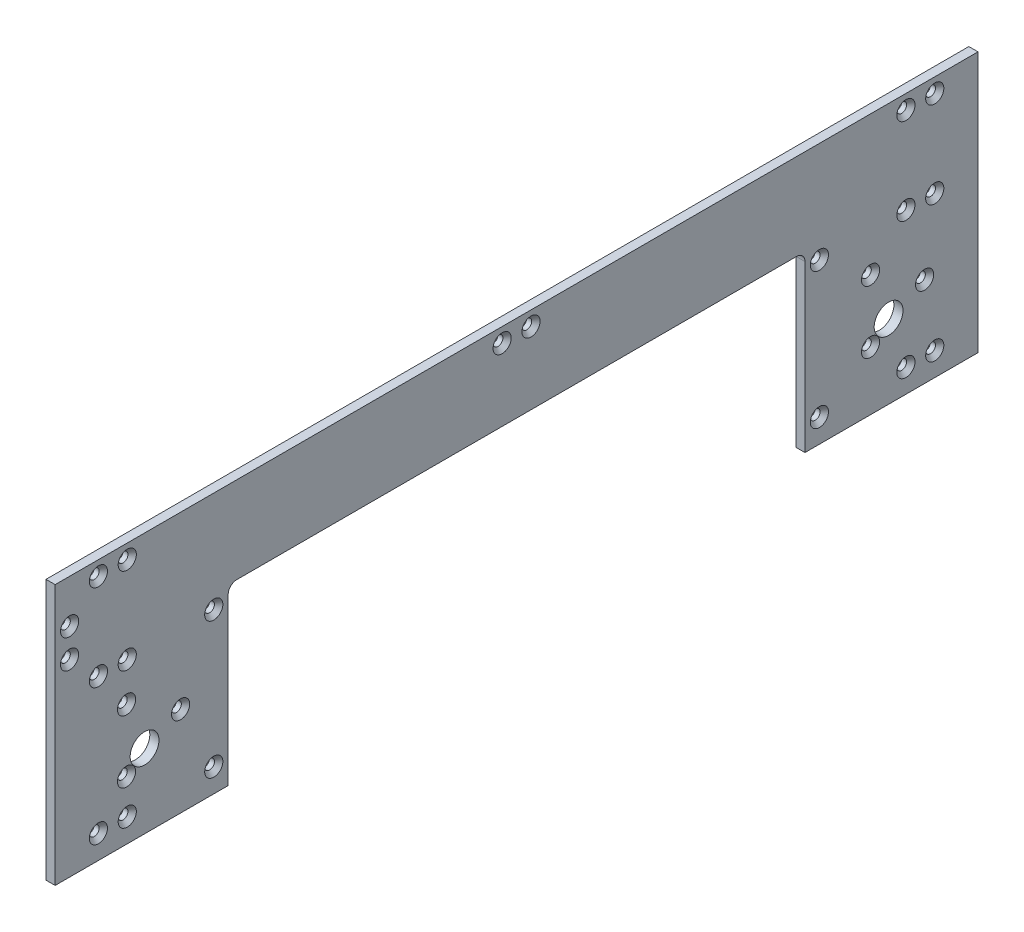
from build123d import *

# Parameters (mm, degrees)
BOSS_EXTRUDE1_DEPTH                             = 3.175
CSK_FOR_M3_FLAT_HEAD_MACHINE_SCREW1_D           = 3.4
CSK_FOR_M3_FLAT_HEAD_MACHINE_SCREW1_CSINK_D     = 6.3
CSK_FOR_M3_FLAT_HEAD_MACHINE_SCREW1_CSINK_ANGLE = 90
SKETCH4_R                                       = 5
CUT_EXTRUDE1_DEPTH                              = 4.175
CSK_FOR_M3_FLAT_HEAD_MACHINE_SCREW2_D           = 3.4
CSK_FOR_M3_FLAT_HEAD_MACHINE_SCREW2_CSINK_D     = 6.3
CSK_FOR_M3_FLAT_HEAD_MACHINE_SCREW2_CSINK_ANGLE = 90
CSK_FOR_M3_FLAT_HEAD_MACHINE_SCREW3_D           = 3.4
CSK_FOR_M3_FLAT_HEAD_MACHINE_SCREW3_CSINK_D     = 6.3
CSK_FOR_M3_FLAT_HEAD_MACHINE_SCREW3_CSINK_ANGLE = 90
LPATTERN1_COUNT                                 = 2
LPATTERN1_PITCH                                 = 258


with BuildPart() as part:
    # Sketch1 → Boss-Extrude1 (new body)
    with BuildSketch(Plane(origin=(0, 0, 0), x_dir=(0, 0, -1), z_dir=(1, 0, 0))):
        Polygon((160, 0), (160, 3.175), (160, 47.175), (160, 50.35), (160, 60.35), (160, 90.35), (-160, 90.35), (-160, 60.35), (-160, 50.35), (-160, 47.175), (-160, 3.175), (-160, 0), align=None)
    extrude(amount=BOSS_EXTRUDE1_DEPTH)

    # CSK for M3 Flat Head Machine Screw1 (through all)
    with Locations(Plane(origin=(3.175, 0, 0), x_dir=(0, 0, -1), z_dir=(1, 0, 0))):
        with Locations((-145, 8.175), (-135, 8.175), (-105, 8.175), (-145, 55.35), (-135, 55.35), (-105, 55.35), (-145, 85.35), (-135, 85.35), (-5, 85.35)):
            csk_for_m3_flat_head_machine_screw1 = CounterSinkHole(CSK_FOR_M3_FLAT_HEAD_MACHINE_SCREW1_D / 2, CSK_FOR_M3_FLAT_HEAD_MACHINE_SCREW1_CSINK_D / 2, counter_sink_angle=CSK_FOR_M3_FLAT_HEAD_MACHINE_SCREW1_CSINK_ANGLE)

    # Mirror1: CSK for M3 Flat Head Machine Screw1 across plane
    add(csk_for_m3_flat_head_machine_screw1.mirror(Plane.XY), mode=Mode.SUBTRACT)

    # Sketch4 → Cut-Extrude1 (cut, through all)
    with BuildSketch(Plane(origin=(3.175, 0, 0), x_dir=(0, 0, -1), z_dir=(1, 0, 0))):
        with Locations((-129, 25.675)):
            Circle(SKETCH4_R)
        with Locations((129, 25.675)):
            Circle(SKETCH4_R)
        with BuildLine():
            Line((-100, 57.35), (-100, 0))
            Line((-100, 0), (100, 0))
            Line((100, 0), (100, 57.35))
            ThreePointArc((100, 57.35), (99.121320344, 59.471320344), (97, 60.35))
            Line((97, 60.35), (-97, 60.35))
            ThreePointArc((-97, 60.35), (-99.121320344, 59.471320344), (-100, 57.35))
        make_face()
    extrude(amount=-CUT_EXTRUDE1_DEPTH, mode=Mode.SUBTRACT)

    # CSK for M3 Flat Head Machine Screw2 (through all)
    with Locations(Plane(origin=(3.175, 0, 0), x_dir=(0, 0, -1), z_dir=(1, 0, 0))):
        with Locations((-155, 65.35), (-155, 75.35)):
            CounterSinkHole(CSK_FOR_M3_FLAT_HEAD_MACHINE_SCREW2_D / 2, CSK_FOR_M3_FLAT_HEAD_MACHINE_SCREW2_CSINK_D / 2, counter_sink_angle=CSK_FOR_M3_FLAT_HEAD_MACHINE_SCREW2_CSINK_ANGLE)

    # CSK for M3 Flat Head Machine Screw3 (through all)
    with Locations(Plane(origin=(3.175, 0, 0), x_dir=(0, 0, -1), z_dir=(1, 0, 0))):
        with Locations((-116.5, 31.175), (-135.25, 20.349682453), (-135.25, 42.000317547)):
            csk_for_m3_flat_head_machine_screw3 = CounterSinkHole(CSK_FOR_M3_FLAT_HEAD_MACHINE_SCREW3_D / 2, CSK_FOR_M3_FLAT_HEAD_MACHINE_SCREW3_CSINK_D / 2, counter_sink_angle=CSK_FOR_M3_FLAT_HEAD_MACHINE_SCREW3_CSINK_ANGLE)

    # LPattern1: CSK for M3 Flat Head Machine Screw3 ×2
    with Locations(*[(0, 0, -i * LPATTERN1_PITCH) for i in range(1, LPATTERN1_COUNT)]):
        add(csk_for_m3_flat_head_machine_screw3, mode=Mode.SUBTRACT)


solid = part.part
